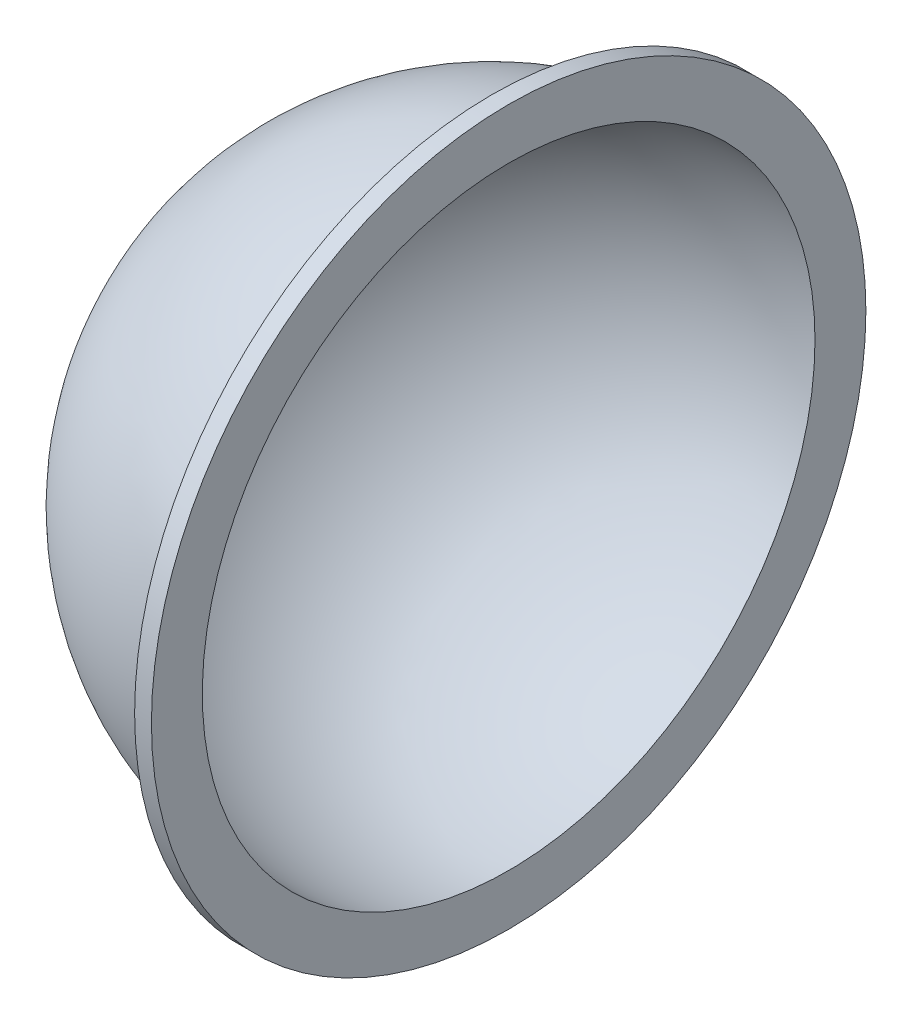
from build123d import *


with BuildPart() as part:
    # Sketch1 → Revolve1 (revolve)
    with BuildSketch(Plane.XY):
        with BuildLine():
            Line((0, 42.5), (0, 37.5))
            ThreePointArc((0, 37.5), (1.000355999, 37.486654797), (2, 37.446628687))
            Line((2, 37.446628687), (2, 42.5))
            Line((2, 42.5), (0, 42.5))
        make_face()
        with BuildLine():
            Line((0, 37.5), (0, 36.5))
            ThreePointArc((0, 36.5), (1.000375799, 36.486288497), (2, 36.445164288))
            Line((2, 36.445164288), (2, 37.446628687))
            ThreePointArc((2, 37.446628687), (1.000355999, 37.486654797), (0, 37.5))
        make_face()
        with BuildLine():
            ThreePointArc((-36.5, 0), (-25.809397513, 25.809397513), (0, 36.5))
            Line((0, 36.5), (0, 37.5))
            ThreePointArc((0, 37.5), (-26.516504294, 26.516504294), (-37.5, 0))
            Line((-37.5, 0), (-36.5, 0))
        make_face()
    revolve(axis=Axis((0, 0, 0), (-1, 0, 0)))


solid = part.part
